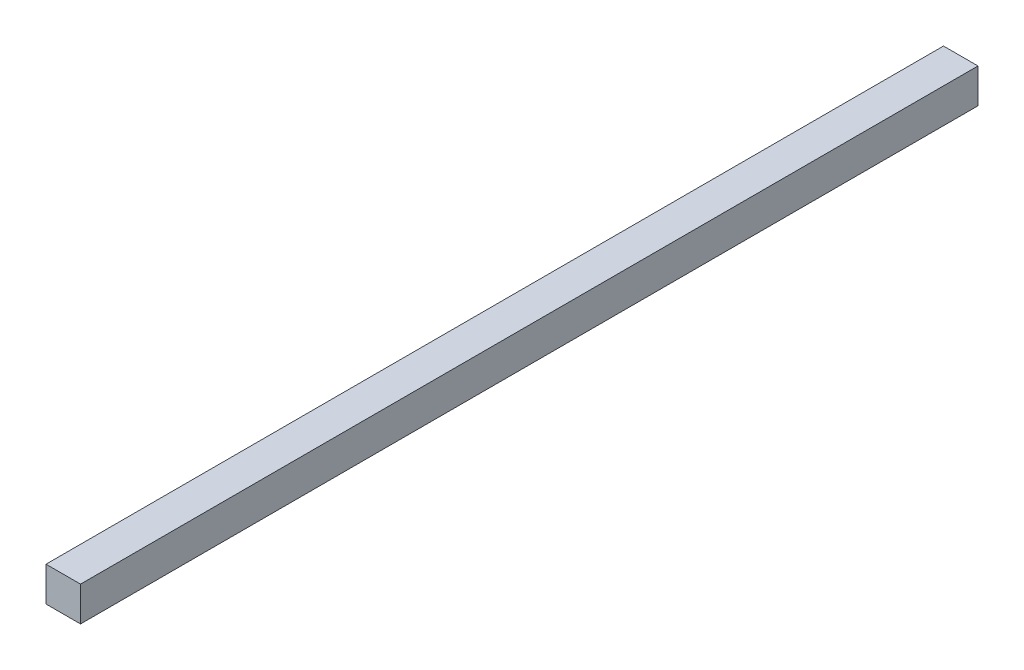
from build123d import *

# Parameters (mm, degrees)
SKETCH1_W           = 25.4
SKETCH1_H           = 25.4
BOSS_EXTRUDE1_DEPTH = 660.4
SKETCH2_R           = 6.35
BOSS_EXTRUDE2_DEPTH = 0.1


with BuildPart() as part:
    # Sketch1 → Boss-Extrude1 (new body)
    with BuildSketch(Plane.XY):
        Rectangle(SKETCH1_W, SKETCH1_H)
    extrude(amount=BOSS_EXTRUDE1_DEPTH)

    # Sketch2 → Boss-Extrude2 (add)
    with BuildSketch(Plane.ZY.offset(12.7)):
        with Locations((647.7, 0)):
            Circle(SKETCH2_R)
        with Locations((12.7, 0)):
            Circle(SKETCH2_R)
    extrude(amount=BOSS_EXTRUDE2_DEPTH)


solid = part.part
